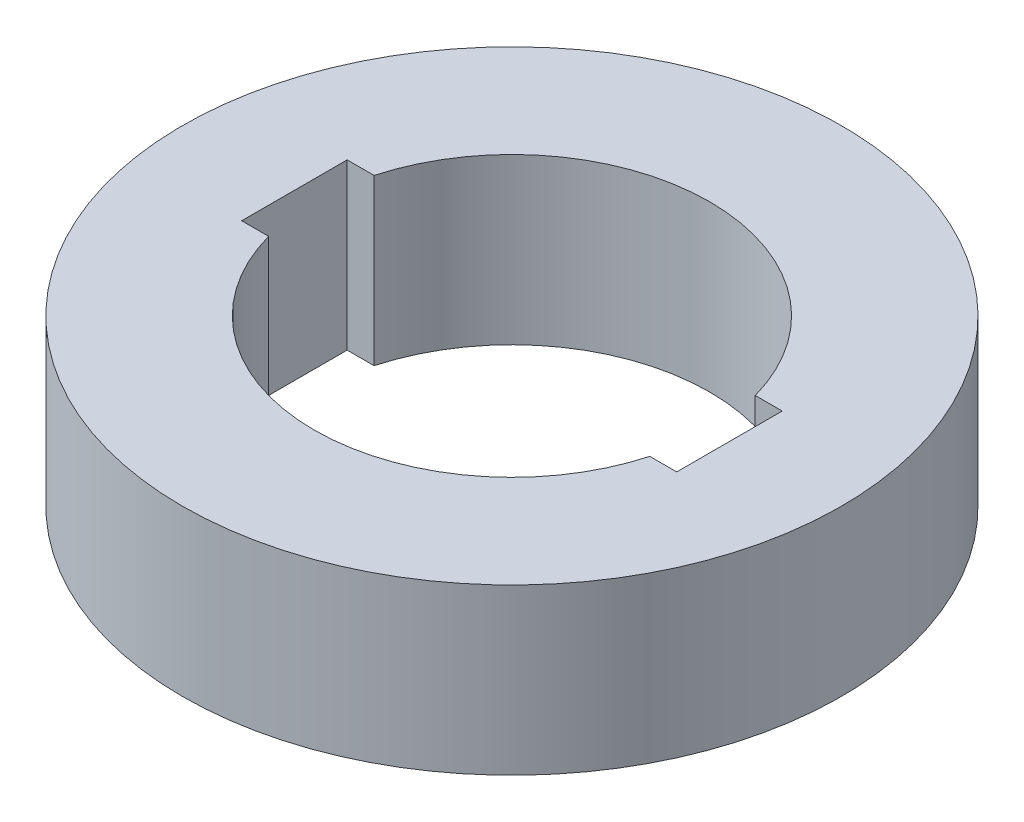
from build123d import *

# Parameters (mm, degrees)
SKETCH1_R           = 50
BOSS_EXTRUDE1_DEPTH = 25


with BuildPart() as part:
    # Sketch1 → Boss-Extrude1 (new body)
    with BuildSketch(Plane(origin=(0, 0, 0), x_dir=(1, 0, 0), z_dir=(0, 1, 0))):
        Circle(SKETCH1_R)
        with BuildLine():
            Line((-28.91366459, -8), (-33, -8))
            Line((-33, -8), (-33, 8))
            Line((-33, 8), (-28.91366459, 8))
            ThreePointArc((-28.91366459, 8), (0, 30), (28.91366459, 8))
            Line((28.91366459, 8), (33, 8))
            Line((33, 8), (33, -8))
            Line((33, -8), (28.91366459, -8))
            ThreePointArc((28.91366459, -8), (0, -30), (-28.91366459, -8))
        make_face(mode=Mode.SUBTRACT)
    extrude(amount=BOSS_EXTRUDE1_DEPTH)


solid = part.part
